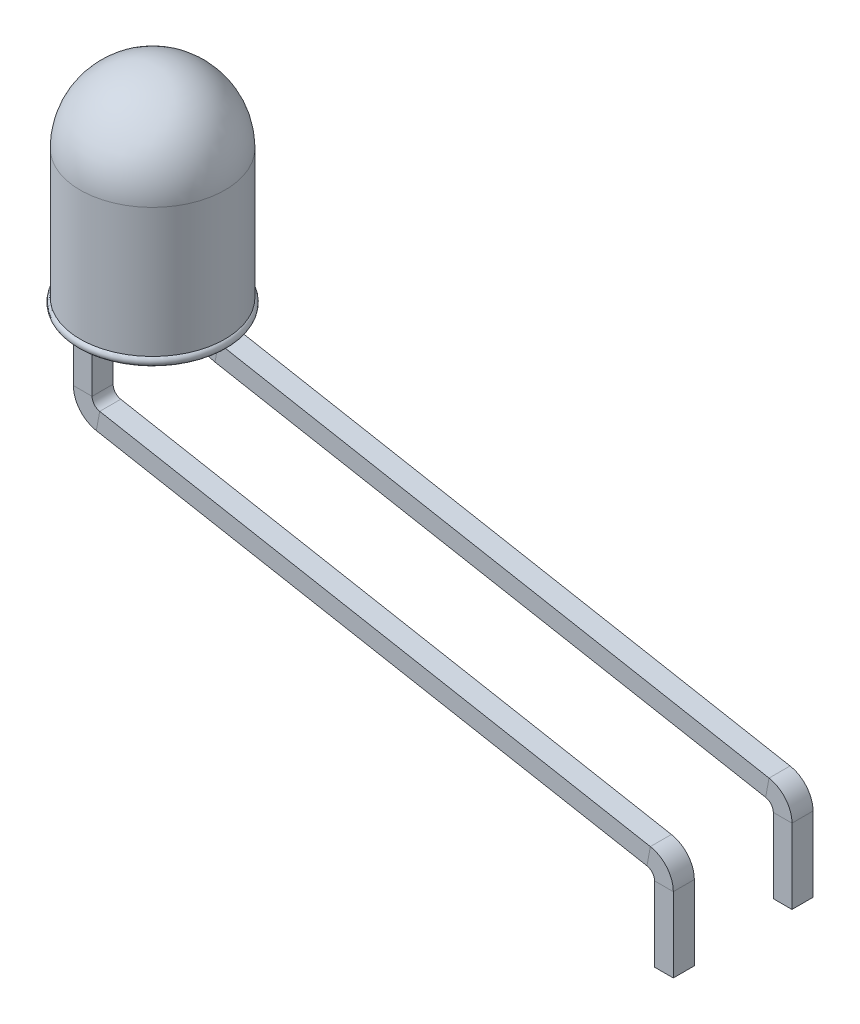
from build123d import *

# Parameters (mm, degrees)
SKETCH2_W = 0.4
SKETCH2_H = 0.45


with BuildPart() as part:
    # Sketch1 → Revolve1 (revolve)
    with BuildSketch(Plane.XY):
        with BuildLine():
            Line((0, 0), (-1.5, 0))
            ThreePointArc((-1.5, 0), (-1.596592583, 0.074118095), (-1.55, 0.18660254))
            Line((-1.55, 0.18660254), (-1.55, 2.95))
            ThreePointArc((-1.55, 2.95), (-1.096015511, 4.046015511), (0, 4.5))
            Line((0, 4.5), (0, 0))
        make_face()
    revolve(axis=Axis((0, 4.5, 0), (0, -1, 0)))

    # Sweep1: sweep along a path in Sketch4
    with BuildLine(Plane.XY) as sweep1_path:
        Line((0, 0), (0, -0.8))
        ThreePointArc((0, -0.8), (0.092564776, -1.055897602), (0.327417914, -1.193359684))
        Line((0.327417914, -1.193359684), (12.112582086, -3.367938908))
        ThreePointArc((12.112582086, -3.367938908), (12.347435224, -3.505400989), (12.44, -3.761298592))
        Line((12.44, -3.761298592), (12.44, -5.361298592))
    # Sketch2 → Sweep1 (sweep)
    with BuildSketch(Plane.XZ):
        with Locations((0, 1.27)):
            Rectangle(SKETCH2_W, SKETCH2_H)
        with Locations((0, -1.27)):
            Rectangle(SKETCH2_W, SKETCH2_H)
    sweep(path=sweep1_path.line)


solid = part.part
